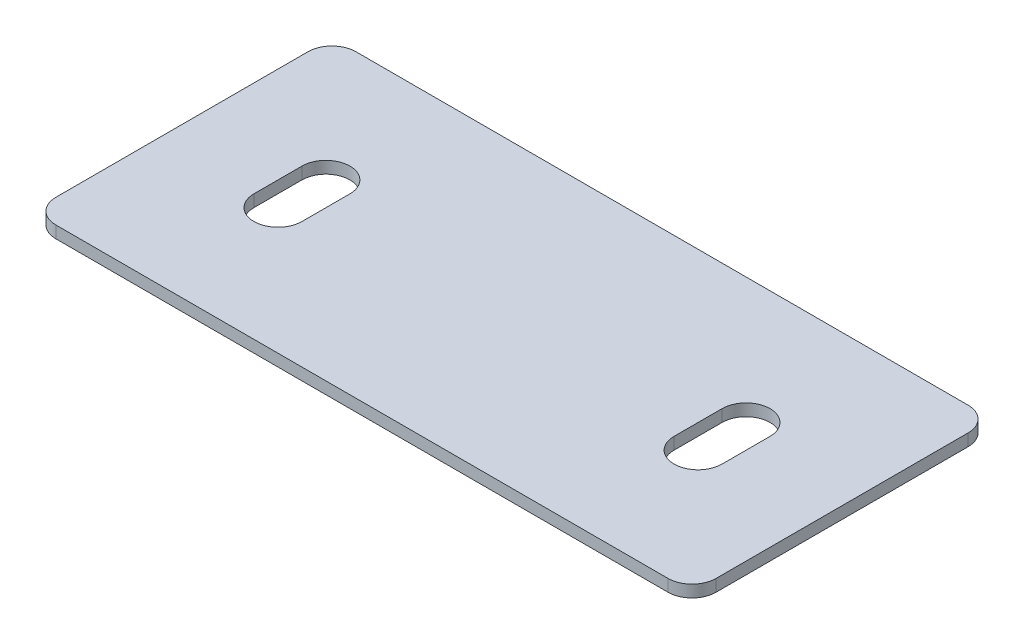
from build123d import *

# Parameters (mm, degrees)
SKETCH_1_W      = 55
SKETCH_1_H      = 25
EXTRUDE_1_DEPTH = 1
FILLET_1_R      = 2


with BuildPart() as part:
    # Эскиз1 → Бобышка-Вытянуть1 (new body)
    with BuildSketch(Plane(origin=(0, 0, 0), x_dir=(1, 0, 0), z_dir=(0, 1, 0))):
        with Locations((-2.718269759, 0.212657213)):
            Rectangle(SKETCH_1_W, SKETCH_1_H)
        with BuildLine():
            Line((-18.218269759, 2.212657213), (-18.218269759, -1.787342787))
            ThreePointArc((-18.218269759, -1.787342787), (-20.218269759, -3.787342787), (-22.218269759, -1.787342787))
            Line((-22.218269759, -1.787342787), (-22.218269759, 2.212657213))
            ThreePointArc((-22.218269759, 2.212657213), (-20.218269759, 4.212657213), (-18.218269759, 2.212657213))
        make_face(mode=Mode.SUBTRACT)
        with BuildLine():
            Line((12.781730241, 2.212657213), (12.781730241, -1.787342787))
            ThreePointArc((12.781730241, -1.787342787), (14.781730241, -3.787342787), (16.781730241, -1.787342787))
            Line((16.781730241, -1.787342787), (16.781730241, 2.212657213))
            ThreePointArc((16.781730241, 2.212657213), (14.781730241, 4.212657213), (12.781730241, 2.212657213))
        make_face(mode=Mode.SUBTRACT)
    extrude(amount=EXTRUDE_1_DEPTH)

    # Скругление1
    fillet_1_edges = [part.edges().sort_by_distance(p)[0] for p in [
        (24.781730241, 0.5, 12.287342787),
        (-30.218269759, 0.5, 12.287342787),
        (-30.218269759, 0.5, -12.712657213),
        (24.781730241, 0.5, -12.712657213),
    ]]
    fillet(fillet_1_edges, radius=FILLET_1_R)


solid = part.part
